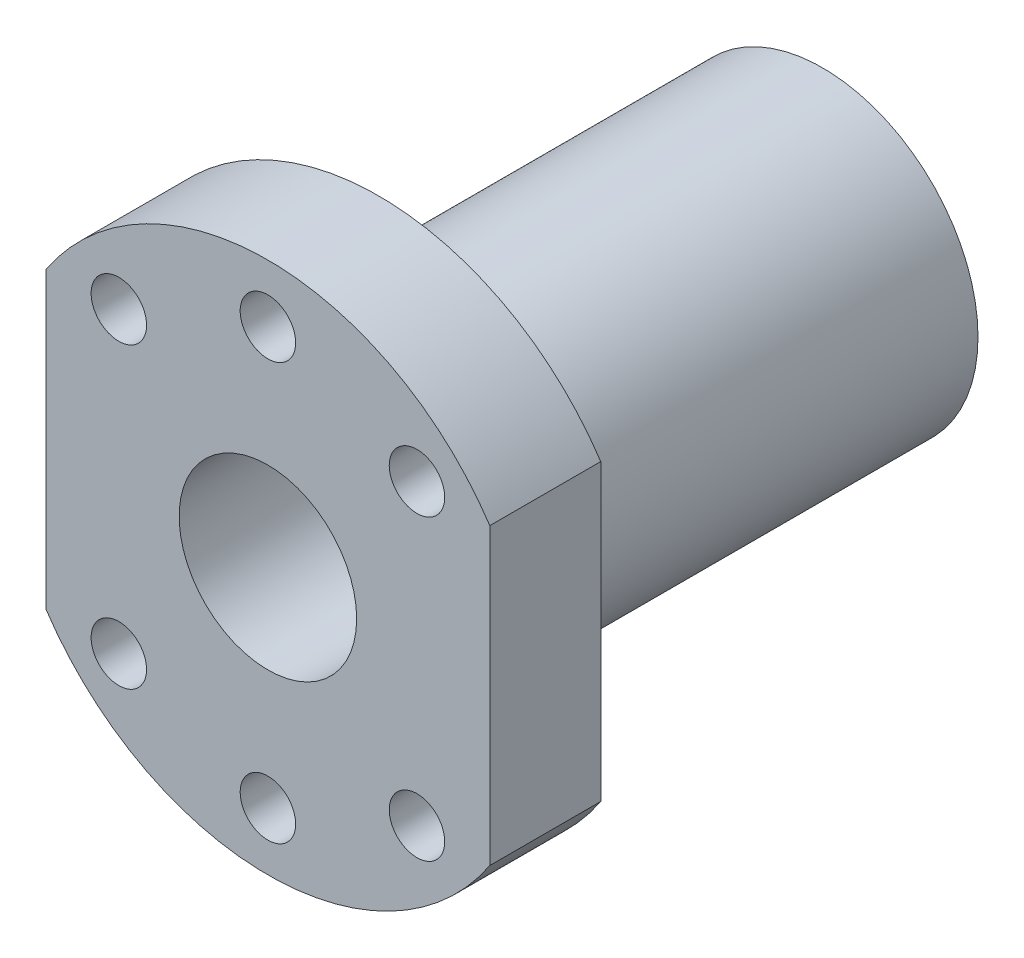
from build123d import *

# Parameters (mm, degrees)
SCHIZZO1_R                   = 8
SCHIZZO1_R_2                 = 2.5
ESTRUSIONE_ESTRUSIONE1_DEPTH = 50
SCHIZZO2_OUTSIDE_W           = 58.004
SCHIZZO2_OUTSIDE_H           = 66.004
SCHIZZO2_OUTSIDE_R           = 14
TAGLIO_ESTRUSIONE1_DEPTH     = 40


with BuildPart() as part:
    # Schizzo1 → Estrusione-Estrusione1 (new body)
    with BuildSketch(Plane.XY):
        with BuildLine():
            Line((20, -13.266499161), (20, 13.266499161))
            ThreePointArc((20, 13.266499161), (0, 24), (-20, 13.266499161))
            Line((-20, 13.266499161), (-20, -13.266499161))
            ThreePointArc((-20, -13.266499161), (0, -24), (20, -13.266499161))
        make_face()
        Circle(SCHIZZO1_R, mode=Mode.SUBTRACT)
        with Locations((-13.435028843, 13.435028843)):
            Circle(SCHIZZO1_R_2, mode=Mode.SUBTRACT)
        with Locations((13.435028843, 13.435028843)):
            Circle(SCHIZZO1_R_2, mode=Mode.SUBTRACT)
        with Locations((13.435028843, -13.435028843)):
            Circle(SCHIZZO1_R_2, mode=Mode.SUBTRACT)
        with Locations((-13.435028843, -13.435028843)):
            Circle(SCHIZZO1_R_2, mode=Mode.SUBTRACT)
        with Locations((0, 18.781867411)):
            Circle(SCHIZZO1_R_2, mode=Mode.SUBTRACT)
        with Locations((0, -18.781867411)):
            Circle(SCHIZZO1_R_2, mode=Mode.SUBTRACT)
    extrude(amount=-ESTRUSIONE_ESTRUSIONE1_DEPTH)

    # Schizzo2 outside → Taglio-Estrusione1 (cut)
    with BuildSketch(Plane(origin=(0, 0, -50), x_dir=(-1, 0, 0), z_dir=(0, 0, -1))):
        Rectangle(SCHIZZO2_OUTSIDE_W, SCHIZZO2_OUTSIDE_H)
        Circle(SCHIZZO2_OUTSIDE_R, mode=Mode.SUBTRACT)
    extrude(amount=-TAGLIO_ESTRUSIONE1_DEPTH, mode=Mode.SUBTRACT)


solid = part.part
